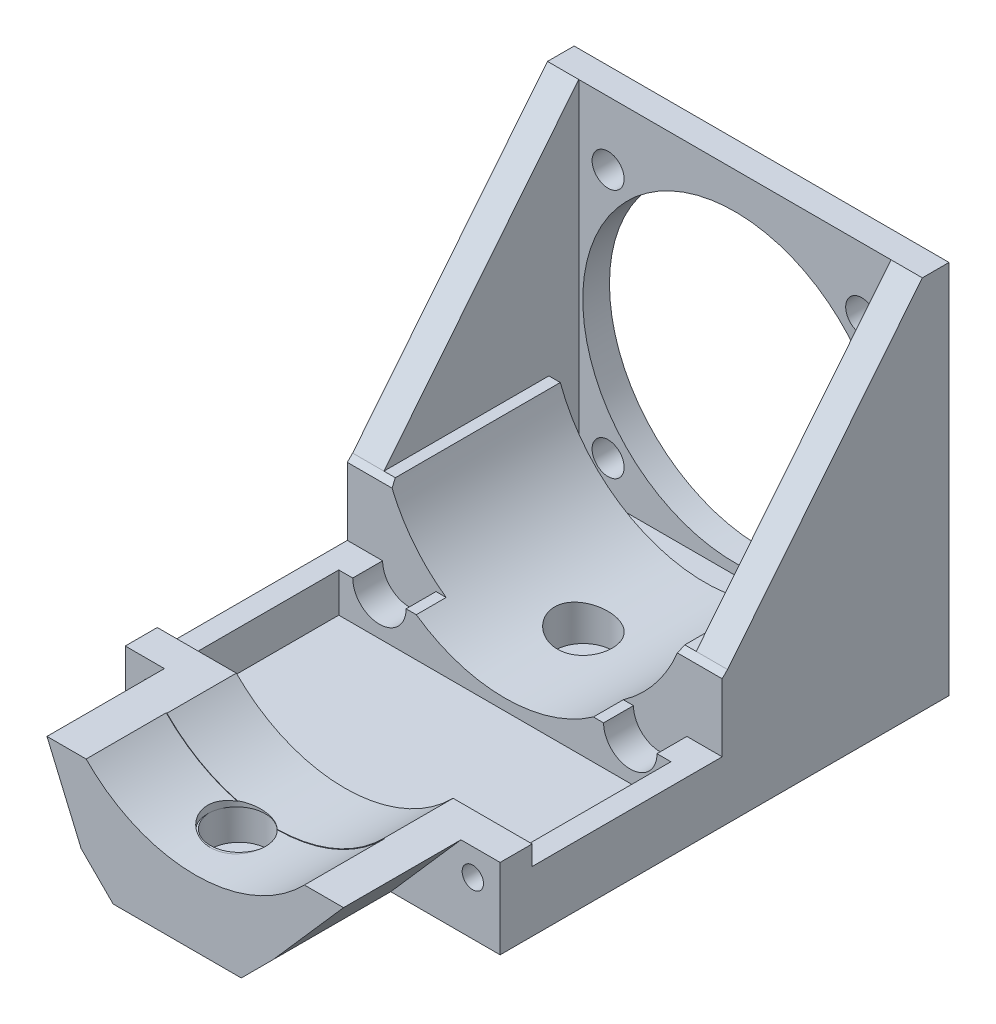
from build123d import *

# Parameters (mm, degrees)
AUFSATZ_LINEAR_AUSTRAGEN1_DEPTH                = 43.1
SKIZZE2_R                                      = 2.55
AUFSATZ_LINEAR_AUSTRAGEN2_DEPTH                = 5
AUFSATZ_LINEAR_AUSTRAGEN2_TAPER                = 10
SCHNITT_LINEAR_AUSTRAGEN1_DEPTH                = 5.6
FASE1_SIZE                                     = 1
SCHNITT_LINEAR_AUSTRAGEN2_DEPTH                = 64.61475613
SCHNITT_LINEAR_AUSTRAGEN2_DEPTH_BACK           = 7.61475613
AUFSATZ_LINEAR_AUSTRAGEN3_DEPTH                = 30
AUFSATZ_LINEAR_AUSTRAGEN4_DEPTH                = 13
AUFSATZ_LINEAR_AUSTRAGEN5_DEPTH                = 15
AUFSATZ_LINEAR_AUSTRAGEN6_DEPTH                = 101.1
F_1_0_1_DURCHMESSER_BOHRUNG1_D                 = 1
F_1_0_1_DURCHMESSER_BOHRUNG1_DEPTH             = 25
F_1_0_1_DURCHMESSER_BOHRUNG1_TIP               = 0.30043031
F_1_0_1_DURCHMESSER_BOHRUNG2_D                 = 1
F_1_0_1_DURCHMESSER_BOHRUNG2_DEPTH             = 25
F_1_0_1_DURCHMESSER_BOHRUNG2_TIP               = 0.30043031
AUFSATZ_LINEAR_AUSTRAGEN7_DEPTH                = 5
SKIZZE48_R                                     = 28.5
SCHNITT_LINEAR_AUSTRAGEN4_DEPTH                = 6
SKIZZE49_W                                     = 58.5
SKIZZE49_H                                     = 5.6
SCHNITT_LINEAR_AUSTRAGEN8_DEPTH                = 20.5
F_6_0_6_DURCHMESSER_BOHRUNG1_D                 = 6
F_6_0_6_DURCHMESSER_BOHRUNG1_DEPTH             = 5
AUFSATZ_LINEAR_AUSTRAGEN8_DEPTH                = 5.864512
AUFSATZ_LINEAR_AUSTRAGEN9_DEPTH                = 5.865
SCHNITT_LINEAR_AUSTRAGEN11_DEPTH               = 22
F_4_0_4_DURCHMESSER_BOHRUNG2_D                 = 4
F_4_0_4_DURCHMESSER_BOHRUNG2_DEPTH             = 6
STIRNSENKUNG_F_R_M5_ZYLINDERSCHRAUBE_3_A_COUNT = 2
STIRNSENKUNG_F_R_M5_ZYLINDERSCHRAUBE_3_A_PITCH = 64.5


with BuildPart() as part:
    # Skizze1 → Aufsatz-Linear austragen1 (new body)
    with BuildSketch(Plane.XY):
        with BuildLine():
            Line((27.11475613, -10), (35.11475613, -10))
            Line((35.11475613, -10), (35.11475613, -35))
            Line((35.11475613, -35), (-35.11475613, -35))
            Line((-35.11475613, -35), (-35.11475613, -10))
            Line((-35.11475613, -10), (-27.11475613, -10))
            ThreePointArc((-27.11475613, -10), (0, -28.9), (27.11475613, -10))
        make_face()
    extrude(amount=AUFSATZ_LINEAR_AUSTRAGEN1_DEPTH)

    # Skizze2 → Aufsatz-Linear austragen2 (add)
    with BuildSketch(Plane(origin=(0, 0, 0), x_dir=(-1, 0, 0), z_dir=(0, 0, -1))):
        with Locations((-23.5, -23.663738082)):
            Circle(SKIZZE2_R)
        with Locations((23.5, -23.663738082)):
            Circle(SKIZZE2_R)
    extrude(amount=AUFSATZ_LINEAR_AUSTRAGEN2_DEPTH, taper=AUFSATZ_LINEAR_AUSTRAGEN2_TAPER)

    # Skizze3 → Schnitt-Linear austragen1 (cut)
    with BuildSketch(Plane.XY.offset(43.1)):
        with BuildLine():
            Line((28.5, -23.663738082), (28.5, -7.705302488))
            Line((28.5, -7.705302488), (-28.5, -7.705302488))
            Line((-28.5, -7.705302488), (-28.5, -23.663738082))
            ThreePointArc((-28.5, -23.663738082), (-23.5, -28.663738082), (-18.5, -23.663738082))
            Line((-18.5, -23.663738082), (-18.5, -22.202702538))
            Line((-18.5, -22.202702538), (18.5, -22.202702538))
            Line((18.5, -22.202702538), (18.5, -23.663738082))
            ThreePointArc((18.5, -23.663738082), (23.5, -28.663738082), (28.5, -23.663738082))
        make_face()
    extrude(amount=-SCHNITT_LINEAR_AUSTRAGEN1_DEPTH, mode=Mode.SUBTRACT)

    # Fase1
    fase1_edges = [part.edges().sort_by_distance(p)[0] for p in [
        (27.807378065, -10, 37.5),
        (-27.807378065, -10, 37.5),
    ]]
    chamfer(fase1_edges, length=FASE1_SIZE)

    # Skizze4 → Schnitt-Linear austragen2 (cut, two sides)
    with BuildSketch(Plane(origin=(-28.5, 0, 0), x_dir=(0, 0, -1), z_dir=(1, 0, 0))) as schnitt_linear_austragen2_sk:
        Polygon((-36.5, -10), (-37.5, -11), (-37.5, -23.663738082), (-43.1, -23.663738082), (-43.1, -10), align=None)
    extrude(amount=SCHNITT_LINEAR_AUSTRAGEN2_DEPTH, mode=Mode.SUBTRACT)
    extrude(schnitt_linear_austragen2_sk.sketch, amount=-SCHNITT_LINEAR_AUSTRAGEN2_DEPTH_BACK, mode=Mode.SUBTRACT)

    # Skizze5 → Aufsatz-Linear austragen3 (add)
    with BuildSketch(Plane.XY.offset(43.1)):
        Polygon((-35.11475613, -35), (-35.11475613, -23.663738082), (-31.11475613, -23.663738082), (-31.11475613, -31), (31.11475613, -31), (31.11475613, -23.663738082), (35.11475613, -23.663738082), (35.11475613, -35), align=None)
    extrude(amount=AUFSATZ_LINEAR_AUSTRAGEN3_DEPTH)

    # Skizze6 → Aufsatz-Linear austragen4 (add)
    with BuildSketch(Plane.XY.offset(73.1)):
        with BuildLine():
            Line((35.11475613, -35), (-35.11475613, -35))
            Line((-35.11475613, -35), (-35.11475613, -20))
            Line((-35.11475613, -20), (-20.303940504, -20))
            ThreePointArc((-20.303940504, -20), (0, -28.5), (20.303940504, -20))
            Line((20.303940504, -20), (35.11475613, -20))
            Line((35.11475613, -20), (35.11475613, -35))
        make_face()
    extrude(amount=AUFSATZ_LINEAR_AUSTRAGEN4_DEPTH)

    # Skizze7 → Aufsatz-Linear austragen5 (add)
    with BuildSketch(Plane.XY.offset(86.1)):
        with BuildLine():
            Line((35.11475613, -35), (-35.11475613, -35))
            Line((-35.11475613, -35), (-35.11475613, -20))
            Line((-35.11475613, -20), (-20.444070045, -20))
            ThreePointArc((-20.444070045, -20), (0, -28.6), (20.444070045, -20))
            Line((20.444070045, -20), (35.11475613, -20))
            Line((35.11475613, -20), (35.11475613, -35))
        make_face()
    extrude(amount=AUFSATZ_LINEAR_AUSTRAGEN5_DEPTH)

    # Skizze24 → Aufsatz-Linear austragen6 (add)
    with BuildSketch(Plane(origin=(0, 0, 0), x_dir=(-1, 0, 0), z_dir=(0, 0, -1))):
        Polygon((-8.62, -41), (-14.62, -35), (21.38, -35), (15.38, -41), align=None)
    extrude(amount=-AUFSATZ_LINEAR_AUSTRAGEN6_DEPTH)

    # Ø1.0 (1) Durchmesser Bohrung1
    with Locations(Plane(origin=(0, -41, 0), x_dir=(-1, 0, 0), z_dir=(0, -1, 0))):
        with Locations((3.38, -25)):
            Hole(F_1_0_1_DURCHMESSER_BOHRUNG1_D / 2, depth=F_1_0_1_DURCHMESSER_BOHRUNG1_DEPTH)
            with Locations((0, 0, -(F_1_0_1_DURCHMESSER_BOHRUNG1_DEPTH + F_1_0_1_DURCHMESSER_BOHRUNG1_TIP / 2))):  # 118° drill point
                Cone(0, F_1_0_1_DURCHMESSER_BOHRUNG1_D / 2, F_1_0_1_DURCHMESSER_BOHRUNG1_TIP, mode=Mode.SUBTRACT)

    # Skizze32 → Stirnsenkung f_r M5 Zylinderschraube mit (revolve, cut)
    with BuildSketch(Plane(origin=(-3.38, -28.9, 25), x_dir=(0, 0, -1), z_dir=(1, 0, 0))):
        Polygon((0, 0), (0, 26.652366702), (2.75, 25), (2.75, 7), (5.4, 7), (5.4, 0), align=None)
    revolve(axis=Axis((-3.38, -35.25, 25), (0, 1, 0)), mode=Mode.SUBTRACT)

    # Ø1.0 (1) Durchmesser Bohrung2
    with Locations(Plane(origin=(0, -41, 0), x_dir=(-1, 0, 0), z_dir=(0, -1, 0))):
        with Locations((3.38, -90)):
            Hole(F_1_0_1_DURCHMESSER_BOHRUNG2_D / 2, depth=F_1_0_1_DURCHMESSER_BOHRUNG2_DEPTH)
            with Locations((0, 0, -(F_1_0_1_DURCHMESSER_BOHRUNG2_DEPTH + F_1_0_1_DURCHMESSER_BOHRUNG2_TIP / 2))):  # 118° drill point
                Cone(0, F_1_0_1_DURCHMESSER_BOHRUNG2_D / 2, F_1_0_1_DURCHMESSER_BOHRUNG2_TIP, mode=Mode.SUBTRACT)

    # Skizze41 → Stirnsenkung f_r M5 Zylinderschraube 2 (revolve, cut)
    with BuildSketch(Plane(origin=(-3.38, -28.6, 90), x_dir=(0, 0, -1), z_dir=(1, 0, 0))):
        Polygon((0, 0), (0, 26.652366702), (2.75, 25), (2.75, 7), (5.4, 7), (5.4, 0), align=None)
    revolve(axis=Axis((-3.38, -34.95, 90), (0, 1, 0)), mode=Mode.SUBTRACT)

    # Skizze45 → Aufsatz-Linear austragen7 (add)
    with BuildSketch(Plane(origin=(0, 0, 0), x_dir=(-1, 0, 0), z_dir=(0, 0, -1))):
        Polygon((-35.11475613, -35), (-14.62, -35), (-8.62, -41), (15.38, -41), (21.38, -35), (35.11475613, -35), (35.11475613, 35.295549341), (-35.11475613, 35.295549341), align=None)
    extrude(amount=AUFSATZ_LINEAR_AUSTRAGEN7_DEPTH)

    # Skizze48 → Schnitt-Linear austragen4 (cut, through all)
    with BuildSketch(Plane.XY):
        Circle(SKIZZE48_R)
    extrude(amount=-SCHNITT_LINEAR_AUSTRAGEN4_DEPTH, mode=Mode.SUBTRACT)

    # Skizze49 → Schnitt-Linear austragen8 (cut)
    with BuildSketch(Plane(origin=(0, -10, 0), x_dir=(1, 0, 0), z_dir=(0, 1, 0))):
        with Locations((-0.00024387, -2.8)):
            Rectangle(SKIZZE49_W, SKIZZE49_H)
    extrude(amount=-SCHNITT_LINEAR_AUSTRAGEN8_DEPTH, mode=Mode.SUBTRACT)

    # Ø6.0 (6) Durchmesser Bohrung1
    with Locations(Plane(origin=(0, 0, -5), x_dir=(-1, 0, 0), z_dir=(0, 0, -1))):
        with Locations((-23.752539123, 23.39599293), (23.752539123, 23.39599293), (23.752539123, -23.39599293), (-23.752539123, -23.39599293)):
            Hole(F_6_0_6_DURCHMESSER_BOHRUNG1_D / 2, depth=F_6_0_6_DURCHMESSER_BOHRUNG1_DEPTH)

    # Skizze54 → Aufsatz-Linear austragen8 (add)
    with BuildSketch(Plane.ZY.offset(35.11475613)):
        Polygon((0, 35.295549341), (36.5, -10), (0, -10), align=None)
    extrude(amount=-AUFSATZ_LINEAR_AUSTRAGEN8_DEPTH)

    # Skizze55 → Aufsatz-Linear austragen9 (add)
    with BuildSketch(Plane(origin=(35.11475613, 0, 0), x_dir=(0, 0, -1), z_dir=(1, 0, 0))):
        Polygon((0, 35.295549341), (0, -10), (-36.5, -10), align=None)
    extrude(amount=-AUFSATZ_LINEAR_AUSTRAGEN9_DEPTH)

    # Skizze62 → Schnitt-Linear austragen11 (cut)
    with BuildSketch(Plane.XY.offset(101.1)):
        Polygon((-35.11475613, -20), (-27.779413088, -20), (-21.38, -35), (-35.11475613, -35), align=None)
        Polygon((35.11475613, -20), (27.779413088, -20), (14.62, -35), (35.11475613, -35), align=None)
    extrude(amount=-SCHNITT_LINEAR_AUSTRAGEN11_DEPTH, mode=Mode.SUBTRACT)

    # Ø4.0 (4) Durchmesser Bohrung2
    with Locations(Plane.XY.offset(79.1)):
        with Locations((-30, -25), (30, -25)):
            Hole(F_4_0_4_DURCHMESSER_BOHRUNG2_D / 2, depth=F_4_0_4_DURCHMESSER_BOHRUNG2_DEPTH)

    # Skizze68 → Stirnsenkung f_r M5 Zylinderschraube 3 (revolve, cut)
    with BuildSketch(Plane(origin=(-3.38, -28.6, 25), x_dir=(0, 0, 1), z_dir=(1, 0, 0))):
        Polygon((0, 0), (0, 26.59228064), (2.65, 25), (2.65, 6), (5.4, 6), (5.4, 0), align=None)
    stirnsenkung_f_r_m5_zylinderschraube_3 = revolve(axis=Axis((-3.38, -22.25, 25), (0, -1, 0)), mode=Mode.SUBTRACT)

    # Stirnsenkung f_r M5 Zylinderschraube 3 a: Stirnsenkung f_r M5 Zylinderschraube 3 ×2
    with Locations(*[(0, 0, i * STIRNSENKUNG_F_R_M5_ZYLINDERSCHRAUBE_3_A_PITCH) for i in range(1, STIRNSENKUNG_F_R_M5_ZYLINDERSCHRAUBE_3_A_COUNT)]):
        add(stirnsenkung_f_r_m5_zylinderschraube_3, mode=Mode.SUBTRACT)


solid = part.part
